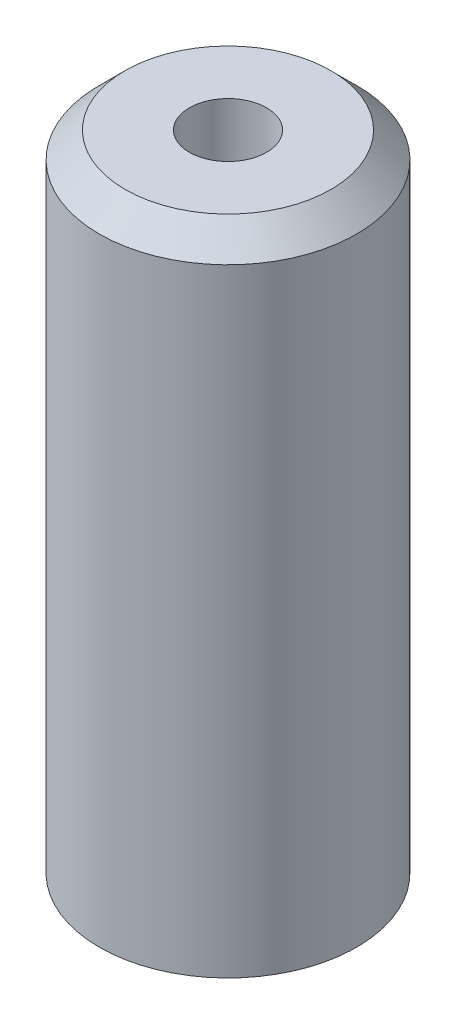
from build123d import *

# Parameters (mm, degrees)
F_6_0_6_DIAMETER_HOLE1_D     = 6
F_6_0_6_DIAMETER_HOLE1_DEPTH = 20
F_6_0_6_DIAMETER_HOLE1_TIP   = 1.802581857
SKETCH6_R                    = 1.5
CUT_EXTRUDE1_DEPTH           = 26


with BuildPart() as part:
    # Sketch2 → Revolve1 (revolve)
    with BuildSketch(Plane.XY):
        Polygon((0, 0), (4, 0), (5, -1), (5, -25), (0, -25), align=None)
    revolve(axis=Axis((0, 3.584458393, 0), (0, -1, 0)))

    # Ø6.0 (6) Diameter Hole1
    with Locations(Plane(origin=(0, -25, 0), x_dir=(-1, 0, 0), z_dir=(0, -1, 0))):
        with Locations((0, 0)):
            Hole(F_6_0_6_DIAMETER_HOLE1_D / 2, depth=F_6_0_6_DIAMETER_HOLE1_DEPTH)
            with Locations((0, 0, -(F_6_0_6_DIAMETER_HOLE1_DEPTH + F_6_0_6_DIAMETER_HOLE1_TIP / 2))):  # 118° drill point
                Cone(0, F_6_0_6_DIAMETER_HOLE1_D / 2, F_6_0_6_DIAMETER_HOLE1_TIP, mode=Mode.SUBTRACT)

    # Sketch6 → Cut-Extrude1 (cut, through all)
    with BuildSketch(Plane(origin=(0, 0, 0), x_dir=(1, 0, 0), z_dir=(0, 1, 0))):
        Circle(SKETCH6_R)
    extrude(amount=-CUT_EXTRUDE1_DEPTH, mode=Mode.SUBTRACT)


solid = part.part
